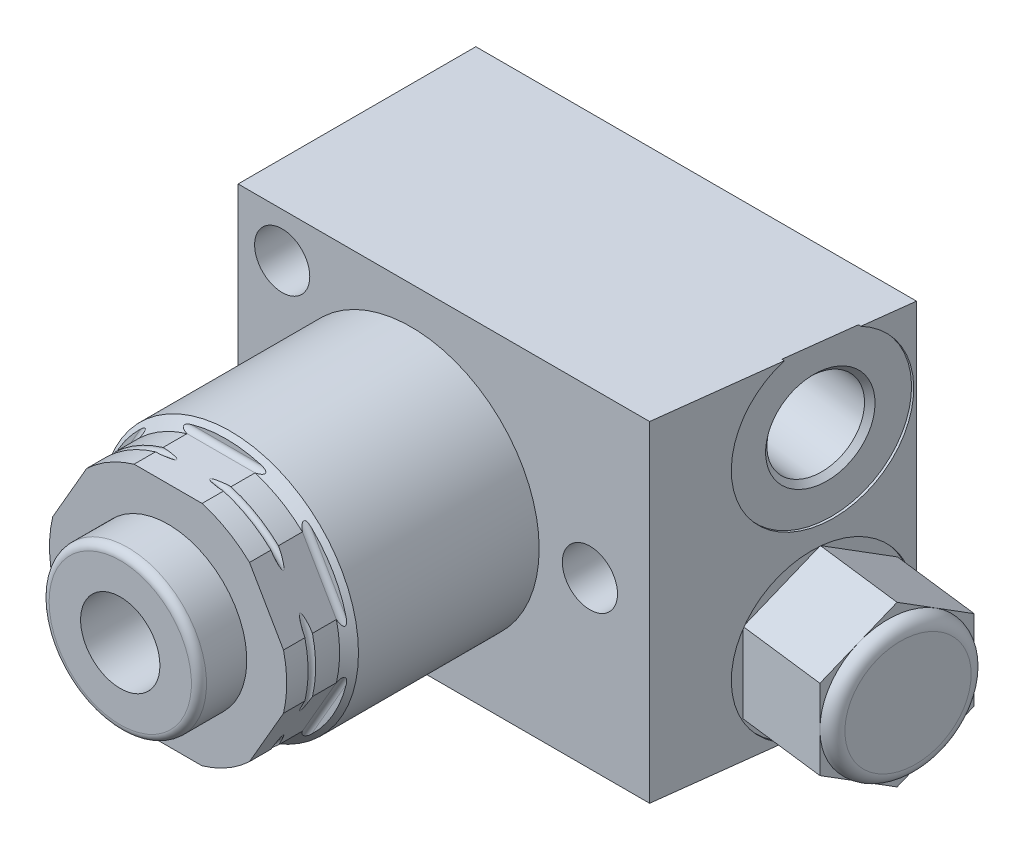
from build123d import *

# Parameters (mm, degrees)
CUT_EXTRUDE1_DEPTH = 13.9159
CIRPATTERN1_COUNT  = 6
EXTRUDE1_DEPTH     = 16.6751
SKETCH4_R          = 4.0005
CUT_EXTRUDE2_DEPTH = 10.541
HOLE1_D            = 5.563
HOLE1_DEPTH        = 23.9776
LPATTERN1_COUNT    = 2
LPATTERN1_PITCH    = 18.3642
EXTRUDE2_DEPTH     = 10.16


with BuildPart() as part:
    # Sketch1 → Revolve1 (revolve)
    with BuildSketch(Plane(origin=(0, 0, 0), x_dir=(0, 0, -1), z_dir=(1, 0, 0)), mode=Mode.PRIVATE) as revolve1_sk:
        Polygon((0, 0), (0, 10.9347), (-2.5908, 10.9347), (-2.5908, 12.0396), (-7.239, 12.0396), (-8.1153, 12.9159), (-33.7185, 12.9159), (-34.671, 11.9634), (-40.005, 11.9634), (-40.005, 0), align=None)
    revolve(revolve1_sk.sketch.rotate(Axis((0, 0, 0), (0, 0, -1)), 90), axis=Axis((0, 0, 0), (0, 0, -1)))  # turned: the seam where the file's is

    # Sketch2 → Cut-Extrude1 (cut, symmetric)
    with BuildSketch(Plane(origin=(0, 0, 0), x_dir=(0, 0, -1), z_dir=(1, 0, 0))):
        with BuildLine():
            Line((-40.005, 11.46175), (-34.671, 11.46175))
            ThreePointArc((-34.671, 11.46175), (-34.311789755, 11.610539755), (-34.163, 11.96975))
            Line((-34.163, 11.96975), (-34.163, 14.63675))
            Line((-34.163, 14.63675), (-40.005, 14.63675))
            Line((-40.005, 14.63675), (-40.005, 11.46175))
        make_face()
    cut_extrude1 = extrude(amount=CUT_EXTRUDE1_DEPTH, both=True, mode=Mode.SUBTRACT)

    # CirPattern1: Cut-Extrude1 ×6 about axis
    cirpattern1_axis = Axis((0, 0, 0), (0, 0, 1))
    for i in range(1, CIRPATTERN1_COUNT):
        add(cut_extrude1.rotate(cirpattern1_axis, i * 360 / CIRPATTERN1_COUNT), mode=Mode.SUBTRACT)

    # Sketch6 → Extrude1 (add, symmetric)
    with BuildSketch(Plane(origin=(0, 0, 0), x_dir=(1, 0, 0), z_dir=(0, 1, 0))):
        Polygon((-17.4498, -15.494), (24.056120912, -15.494), (27.0002, 8.4836), (-17.4498, 8.4836), align=None)
    extrude(amount=EXTRUDE1_DEPTH, both=True)

    # Sketch3 → Revolve2 (revolve)
    with BuildSketch(Plane(origin=(0, 0, 0), x_dir=(0, 0, -1), z_dir=(1, 0, 0)), mode=Mode.PRIVATE) as revolve2_sk:
        with BuildLine():
            Line((-44.831, 0), (-44.831, 7.1755))
            ThreePointArc((-44.831, 7.1755), (-44.607815367, 7.714315367), (-44.069, 7.9375))
            Line((-44.069, 7.9375), (-40.005, 7.9375))
            Line((-40.005, 7.9375), (-40.005, 0))
            Line((-40.005, 0), (-44.831, 0))
        make_face()
    revolve(revolve2_sk.sketch.rotate(Axis((0, 0, 0), (0, 0, 1)), 103.349004362), axis=Axis((0, 0, 0), (0, 0, 1)))  # turned: the seam where the file's is

    # Sketch4 → Cut-Extrude2 (cut)
    with BuildSketch(Plane.XY.offset(44.831)):
        Circle(SKETCH4_R)
    extrude(amount=-CUT_EXTRUDE2_DEPTH, mode=Mode.SUBTRACT)

    # Sketch5 → Cut-Revolve1 (revolve, cut)
    with BuildSketch(Plane(origin=(0, 0, 0), x_dir=(0, 0, -1), z_dir=(1, 0, 0)), mode=Mode.PRIVATE) as cut_revolve1_sk:
        with BuildLine():
            Line((-37.846, 15.1384), (-37.846, 11.9634))
            ThreePointArc((-37.846, 11.9634), (-37.465, 11.5824), (-37.084, 11.9634))
            Line((-37.084, 11.9634), (-37.084, 15.1384))
            Line((-37.084, 15.1384), (-37.846, 15.1384))
        make_face()
    revolve(cut_revolve1_sk.sketch.rotate(Axis((0, 0, 0), (0, 0, 1)), 103.349004362), axis=Axis((0, 0, 0), (0, 0, 1)), mode=Mode.SUBTRACT)  # turned: the seam where the file's is

    # Hole1
    with Locations(Plane.XY.offset(15.494)):
        with Locations((-13.0048, 12.192), (-13.0048, -12.192), (18.034, 0)):
            Hole(HOLE1_D / 2, depth=HOLE1_DEPTH)

    # Sketch9 → Cut-Revolve2 (revolve, cut)
    with BuildSketch(Plane(origin=(0, -9.1821, 0), x_dir=(-1, 0, 0), z_dir=(0, 1, 0)), mode=Mode.PRIVATE) as cut_revolve2_sk:
        Polygon((-24.957182327, 8.155443686), (-24.705075605, 8.124488873), (-25.107488177, 4.84710148), (-24.643069167, 4.252672255), (-14.684853628, 3.029957133), (-15.223467378, -1.356699839), (-25.963213757, -0.038024796), align=None)
    cut_revolve2 = revolve(cut_revolve2_sk.sketch.rotate(Axis((25.963213757, -9.1821, -0.038024796), (-0.992546152, 0, -0.121869343)), 180), axis=Axis((25.963213757, -9.1821, -0.038024796), (-0.992546152, 0, -0.121869343)), mode=Mode.SUBTRACT)  # turned: the seam where the file's is

    # LPattern1: Cut-Revolve2 ×2
    with Locations(*[(0, i * LPATTERN1_PITCH, 0) for i in range(1, LPATTERN1_COUNT)]):
        add(cut_revolve2, mode=Mode.SUBTRACT)

    # Sketch10 → Extrude2 (add)
    with BuildSketch(Plane(origin=(25.320898315, 0, 3.109015381), x_dir=(0.121869343, 0, -0.992546152), z_dir=(0.992546152, 0, 0.121869343))):
        Polygon((10.186861178, -13.21489163), (10.186861178, -5.14930837), (3.201861178, -1.116516739), (-3.783138822, -5.14930837), (-3.783138822, -13.21489163), (3.201861178, -17.247683261), align=None)
    extrude(amount=EXTRUDE2_DEPTH)

    # Sketch11 → Cut-Revolve3 (revolve, cut)
    with BuildSketch(Plane(origin=(0, -9.1821, 0), x_dir=(-1, 0, 0), z_dir=(0, 1, 0)), mode=Mode.PRIVATE) as cut_revolve3_sk:
        with BuildLine():
            Line((-33.683584959, 7.947373723), (-33.064488694, 12.989508174))
            Line((-33.064488694, 12.989508174), (-36.215822726, 13.376443339))
            Line((-36.215822726, 13.376443339), (-36.989693056, 7.073775276))
            Line((-36.989693056, 7.073775276), (-35.098892638, 6.841614177))
            ThreePointArc((-35.098892638, 6.841614177), (-34.620249099, 7.687613768), (-33.683584959, 7.947373723))
        make_face()
    revolve(cut_revolve3_sk.sketch.rotate(Axis((52.21525093, -9.1821, 3.185320061), (-0.992546152, 0, -0.121869343)), 180), axis=Axis((52.21525093, -9.1821, 3.185320061), (-0.992546152, 0, -0.121869343)), mode=Mode.SUBTRACT)  # turned: the seam where the file's is


solid = part.part
